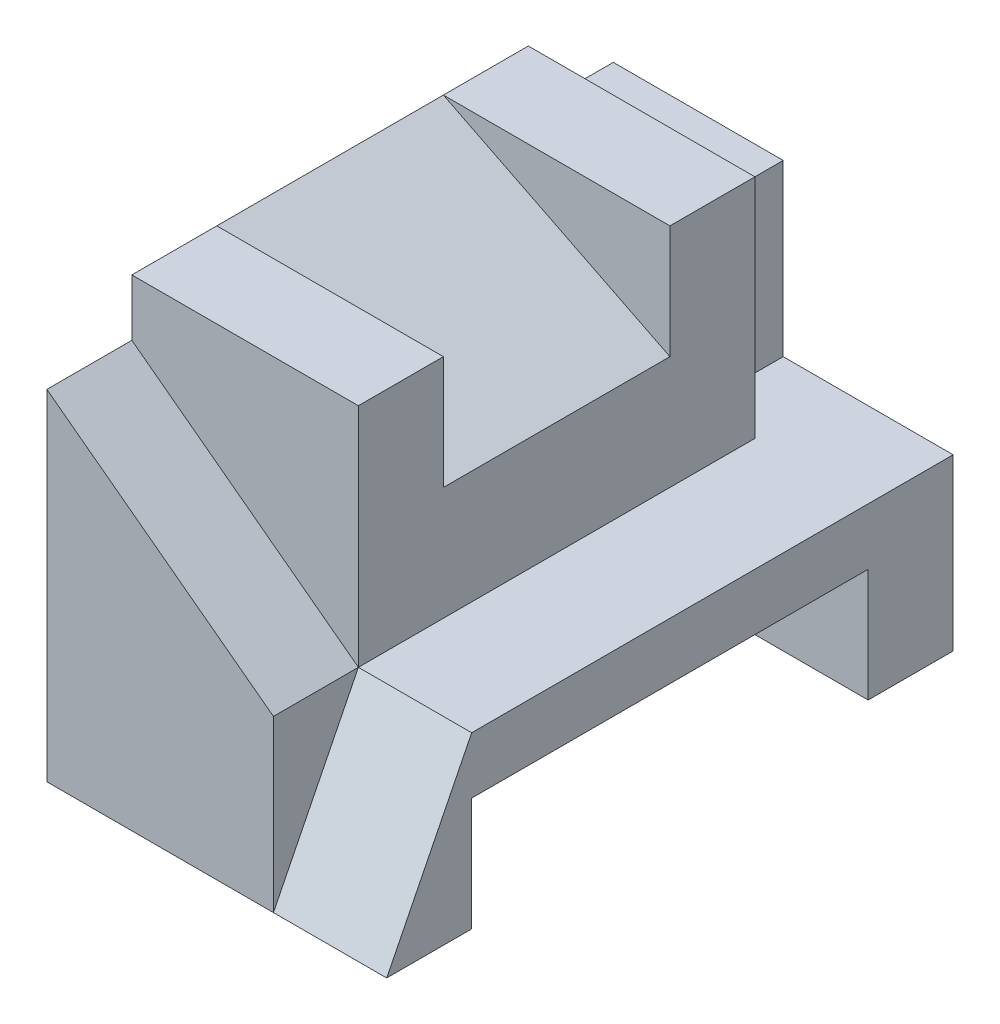
from build123d import *

# Parameters (mm, degrees)
SALIENTE_EXTRUIR2_DEPTH = 6
CORTAR_EXTRUIR2_DEPTH   = 2
CROQUIS6_W              = 4
CROQUIS6_H              = 8
SALIENTE_EXTRUIR3_DEPTH = 4
CORTAR_EXTRUIR3_DEPTH   = 1.5
CROQUIS9_W              = 4
CROQUIS9_H              = 2
CORTAR_EXTRUIR4_DEPTH   = 5
CROQUIS10_W             = 1.5
CROQUIS10_H             = 4
SALIENTE_EXTRUIR4_DEPTH = 4
SALIENTE_EXTRUIR5_DEPTH = 4
CROQUIS13_W             = 3
CROQUIS13_H             = 3
SALIENTE_EXTRUIR6_DEPTH = 1.5


with BuildPart() as part:
    # Croquis2 → Saliente-Extruir2 (new body)
    with BuildSketch(Plane(origin=(0, 0, 0), x_dir=(0, 0, -1), z_dir=(1, 0, 0))):
        Polygon((0, 0), (0, -3), (1.5, -3), (1.5, -1), (8.5, -1), (8.5, -3), (10, -3), (10, 0), align=None)
    extrude(amount=SALIENTE_EXTRUIR2_DEPTH)

    # Croquis5 → Cortar-Extruir2 (cut)
    with BuildSketch(Plane(origin=(6, 0, 0), x_dir=(0, 0, -1), z_dir=(1, 0, 0))):
        Polygon((0, -3), (1.5, 0), (0, 0), align=None)
    extrude(amount=-CORTAR_EXTRUIR2_DEPTH, mode=Mode.SUBTRACT)

    # Croquis6 → Saliente-Extruir3 (add)
    with BuildSketch(Plane(origin=(0, 0, 0), x_dir=(1, 0, 0), z_dir=(0, 1, 0))):
        with Locations((2, 4)):
            Rectangle(CROQUIS6_W, CROQUIS6_H)
    extrude(amount=SALIENTE_EXTRUIR3_DEPTH)

    # Croquis7 → Cortar-Extruir3 (cut)
    with BuildSketch(Plane.XY):
        Polygon((0, 3), (4, 0), (4, 4), (0, 4), align=None)
    extrude(amount=-CORTAR_EXTRUIR3_DEPTH, mode=Mode.SUBTRACT)

    # Croquis9 → Cortar-Extruir4 (cut)
    with BuildSketch(Plane(origin=(4, 0, 0), x_dir=(0, 0, -1), z_dir=(1, 0, 0))):
        with Locations((5, 3)):
            Rectangle(CROQUIS9_W, CROQUIS9_H)
    extrude(amount=-CORTAR_EXTRUIR4_DEPTH, mode=Mode.SUBTRACT)

    # Croquis10 → Saliente-Extruir4 (add)
    with BuildSketch(Plane(origin=(4, 0, 0), x_dir=(0, 0, -1), z_dir=(1, 0, 0))):
        with Locations((7.75, 2)):
            Rectangle(CROQUIS10_W, CROQUIS10_H)
    extrude(amount=-SALIENTE_EXTRUIR4_DEPTH)

    # Croquis12 → Saliente-Extruir5 (add)
    with BuildSketch(Plane.XY.offset(-7)):
        Polygon((0, 4), (4, 2), (0, 2), align=None)
    extrude(amount=SALIENTE_EXTRUIR5_DEPTH)

    # Croquis13 → Saliente-Extruir6 (add)
    with BuildSketch(Plane(origin=(0, 0, -8.5), x_dir=(-1, 0, 0), z_dir=(0, 0, -1))):
        with Locations((-1.5, 1.5)):
            Rectangle(CROQUIS13_W, CROQUIS13_H)
    extrude(amount=SALIENTE_EXTRUIR6_DEPTH)


solid = part.part
